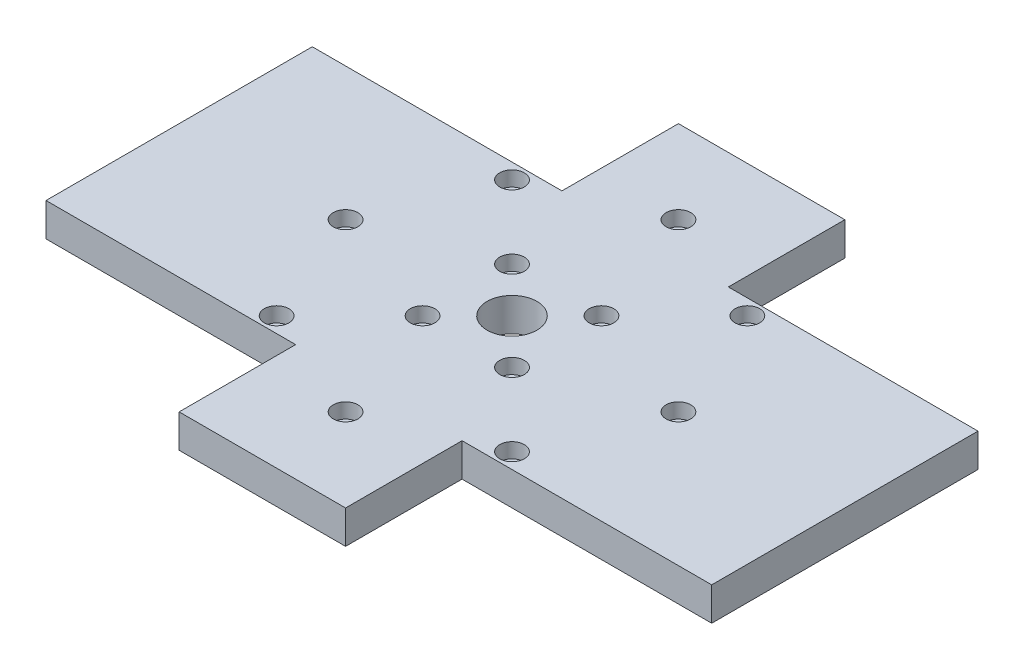
from build123d import *

# Parameters (mm, degrees)
SKETCH_1_W          = 200
SKETCH_1_H          = 80
EXTRUDE_1_DEPTH     = 10
SKETCH_3_W          = 50
SKETCH_3_H          = 150
EXTRUDE_2_DEPTH     = 10
SKETCH_5_R          = 1.7
SKETCH_5_R_2        = 7.5
CUT_EXTRUDE_3_DEPTH = 10
SKETCH_6_R          = 1.7
CUT_EXTRUDE_4_DEPTH = 10
SKETCH_7_R          = 3.7
CUT_EXTRUDE_5_DEPTH = 4.5


with BuildPart() as part:
    # 草图1 → 凸台-拉伸1 (new body)
    with BuildSketch(Plane(origin=(0, 0, 0), x_dir=(1, 0, 0), z_dir=(0, 1, 0))):
        Rectangle(SKETCH_1_W, SKETCH_1_H)
    extrude(amount=EXTRUDE_1_DEPTH)

    # 草图3 → 凸台-拉伸2 (add)
    with BuildSketch(Plane(origin=(0, 10, 0), x_dir=(1, 0, 0), z_dir=(0, 1, 0))):
        Rectangle(SKETCH_3_W, SKETCH_3_H)
    extrude(amount=-EXTRUDE_2_DEPTH)

    # 草图5 → 切除-拉伸3 (cut)
    with BuildSketch(Plane(origin=(0, 10, 0), x_dir=(1, 0, 0), z_dir=(0, 1, 0))):
        with Locations((13.435028843, 13.435028843)):
            Circle(SKETCH_5_R)
        with Locations((13.435028843, -13.435028843)):
            Circle(SKETCH_5_R)
        with Locations((-13.435028843, -13.435028843)):
            Circle(SKETCH_5_R)
        with Locations((-13.435028843, 13.435028843)):
            Circle(SKETCH_5_R)
        Circle(SKETCH_5_R_2)
    extrude(amount=-CUT_EXTRUDE_3_DEPTH, mode=Mode.SUBTRACT)

    # 草图6 → 切除-拉伸4 (cut)
    with BuildSketch(Plane(origin=(0, 10, 0), x_dir=(1, 0, 0), z_dir=(0, 1, 0))):
        with Locations((0, 50)):
            Circle(SKETCH_6_R)
        with Locations((35.355339059, 35.355339059)):
            Circle(SKETCH_6_R)
        with Locations((50, 0)):
            Circle(SKETCH_6_R)
        with Locations((35.355339059, -35.355339059)):
            Circle(SKETCH_6_R)
        with Locations((0, -50)):
            Circle(SKETCH_6_R)
        with Locations((-35.355339059, -35.355339059)):
            Circle(SKETCH_6_R)
        with Locations((-50, 0)):
            Circle(SKETCH_6_R)
        with Locations((-35.355339059, 35.355339059)):
            Circle(SKETCH_6_R)
    extrude(amount=-CUT_EXTRUDE_4_DEPTH, mode=Mode.SUBTRACT)

    # 草图7 → 切除-拉伸5 (cut)
    with BuildSketch(Plane(origin=(0, 10, 0), x_dir=(1, 0, 0), z_dir=(0, 1, 0))):
        with Locations((0, 50)):
            Circle(SKETCH_7_R)
        with Locations((13.435028843, 13.435028843)):
            Circle(SKETCH_7_R)
        with Locations((35.355339059, 35.355339059)):
            Circle(SKETCH_7_R)
        with Locations((50, 0)):
            Circle(SKETCH_7_R)
        with Locations((35.355339059, -35.355339059)):
            Circle(SKETCH_7_R)
        with Locations((0, -50)):
            Circle(SKETCH_7_R)
        with Locations((-35.355339059, -35.355339059)):
            Circle(SKETCH_7_R)
        with Locations((-50, 0)):
            Circle(SKETCH_7_R)
        with Locations((-35.355339059, 35.355339059)):
            Circle(SKETCH_7_R)
        with Locations((13.435028843, -13.435028843)):
            Circle(SKETCH_7_R)
        with Locations((-13.435028843, -13.435028843)):
            Circle(SKETCH_7_R)
        with Locations((-13.435028843, 13.435028843)):
            Circle(SKETCH_7_R)
    extrude(amount=-CUT_EXTRUDE_5_DEPTH, mode=Mode.SUBTRACT)


solid = part.part
